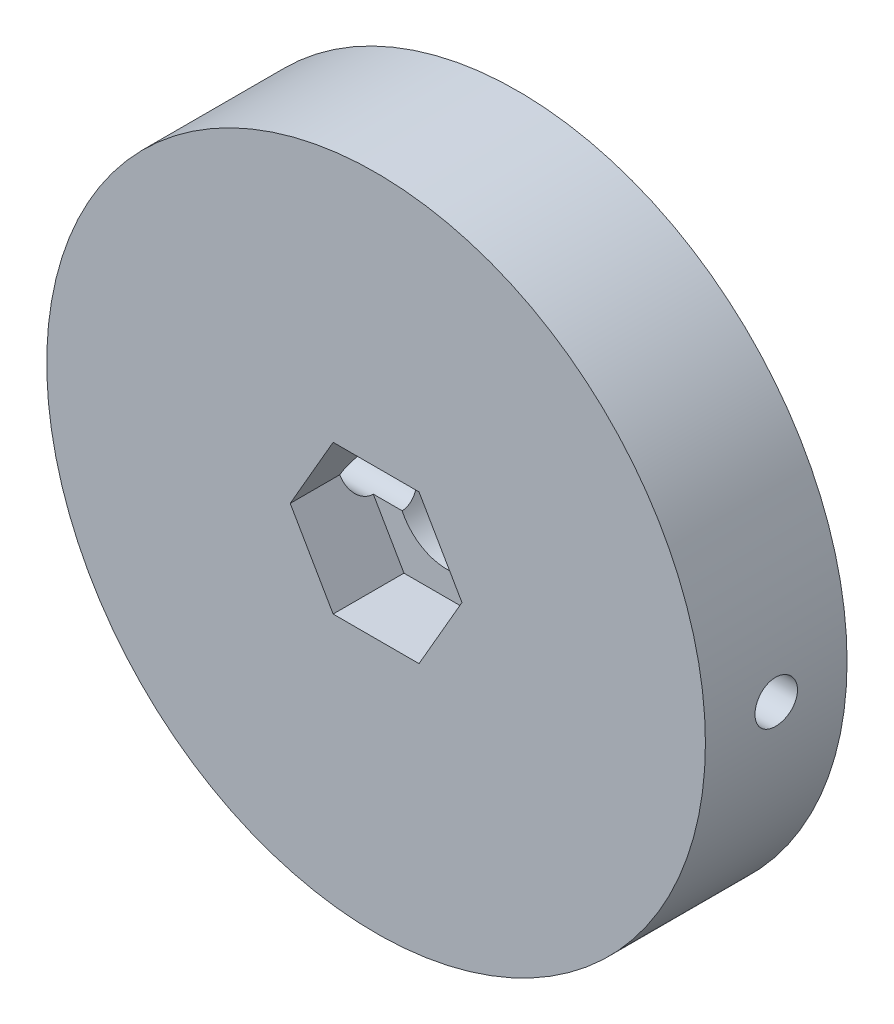
from build123d import *

# Parameters (mm, degrees)
SKETCH_1_R               = 23.25
SKETCH_1_R_2             = 3.5
EXTRUDE_1_DEPTH          = 10
SKETCH_2_R               = 1.5
CUT_EXTRUDE_1_DEPTH      = 24.25
CUT_EXTRUDE_1_DEPTH_BACK = 24.25
CUT_EXTRUDE_3_DEPTH      = 5


with BuildPart() as part:
    # Эскиз1 → Бобышка-Вытянуть1 (new body)
    with BuildSketch(Plane.XY):
        Circle(SKETCH_1_R)
        Circle(SKETCH_1_R_2, mode=Mode.SUBTRACT)
    extrude(amount=EXTRUDE_1_DEPTH)

    # Эскиз2 → Вырез-Вытянуть1 (cut, two sides)
    with BuildSketch(Plane(origin=(0, 0, 0), x_dir=(0, 0, -1), z_dir=(1, 0, 0))) as cut_extrude_1_sk:
        with Locations((-5, 0)):
            Circle(SKETCH_2_R)
    extrude(amount=CUT_EXTRUDE_1_DEPTH, mode=Mode.SUBTRACT)
    extrude(cut_extrude_1_sk.sketch, amount=-CUT_EXTRUDE_1_DEPTH_BACK, mode=Mode.SUBTRACT)

    # Эскиз3 → Вырез-Вытянуть3 (cut)
    with BuildSketch(Plane.XY.offset(10)):
        Polygon((3.031088913, 5.25), (-3.031088913, 5.25), (-6.062177826, 0), (-3.031088913, -5.25), (3.031088913, -5.25), (6.062177826, 0), align=None)
    extrude(amount=-CUT_EXTRUDE_3_DEPTH, mode=Mode.SUBTRACT)


solid = part.part
